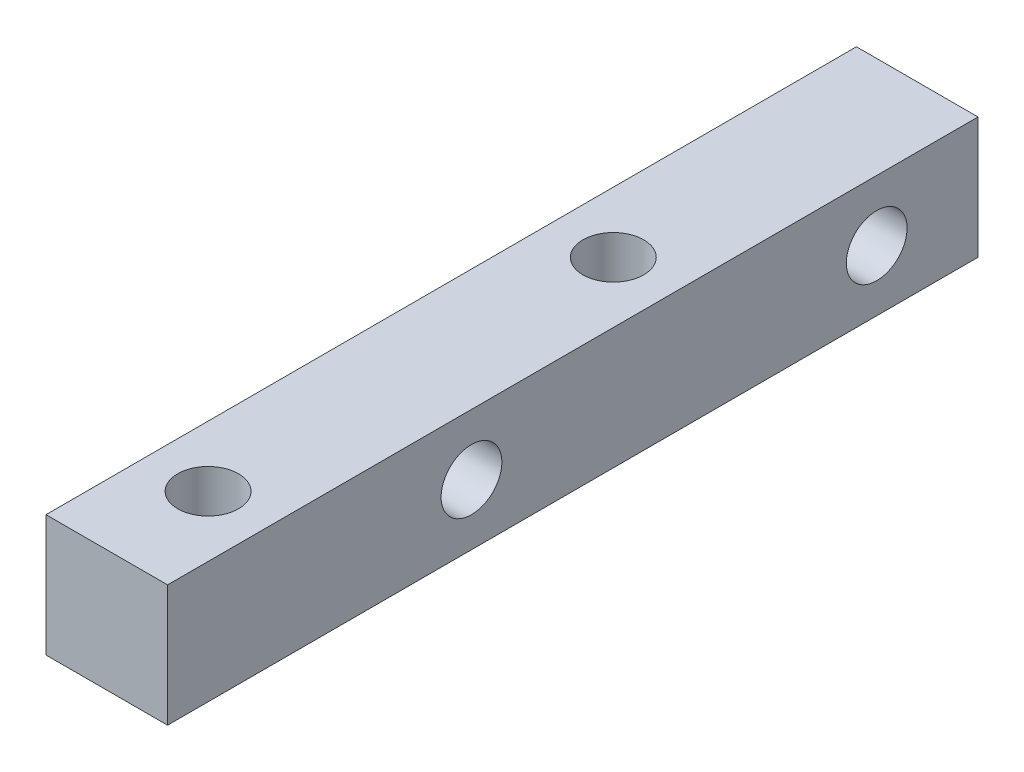
from build123d import *

# Parameters (mm, degrees)
SKETCH_1_W          = 6
SKETCH_1_H          = 6
EXTRUDE_1_DEPTH     = 40
SKETCH_2_R          = 1.5
CUT_EXTRUDE_1_DEPTH = 7
SKETCH_3_R          = 1.5
CUT_EXTRUDE_2_DEPTH = 7


with BuildPart() as part:
    # 草图1 → 凸台-拉伸1 (new body)
    with BuildSketch(Plane.XY):
        Rectangle(SKETCH_1_W, SKETCH_1_H)
    extrude(amount=EXTRUDE_1_DEPTH)

    # 草图2 → 切除-拉伸1 (cut, through all)
    with BuildSketch(Plane.ZY.offset(3)):
        with Locations((5, 0)):
            Circle(SKETCH_2_R)
        with Locations((25, 0)):
            Circle(SKETCH_2_R)
    extrude(amount=-CUT_EXTRUDE_1_DEPTH, mode=Mode.SUBTRACT)

    # 草图3 → 切除-拉伸2 (cut, through all)
    with BuildSketch(Plane(origin=(0, 3, 0), x_dir=(1, 0, 0), z_dir=(0, 1, 0))):
        with Locations((0, -15)):
            Circle(SKETCH_3_R)
        with Locations((0, -35)):
            Circle(SKETCH_3_R)
    extrude(amount=-CUT_EXTRUDE_2_DEPTH, mode=Mode.SUBTRACT)


solid = part.part
